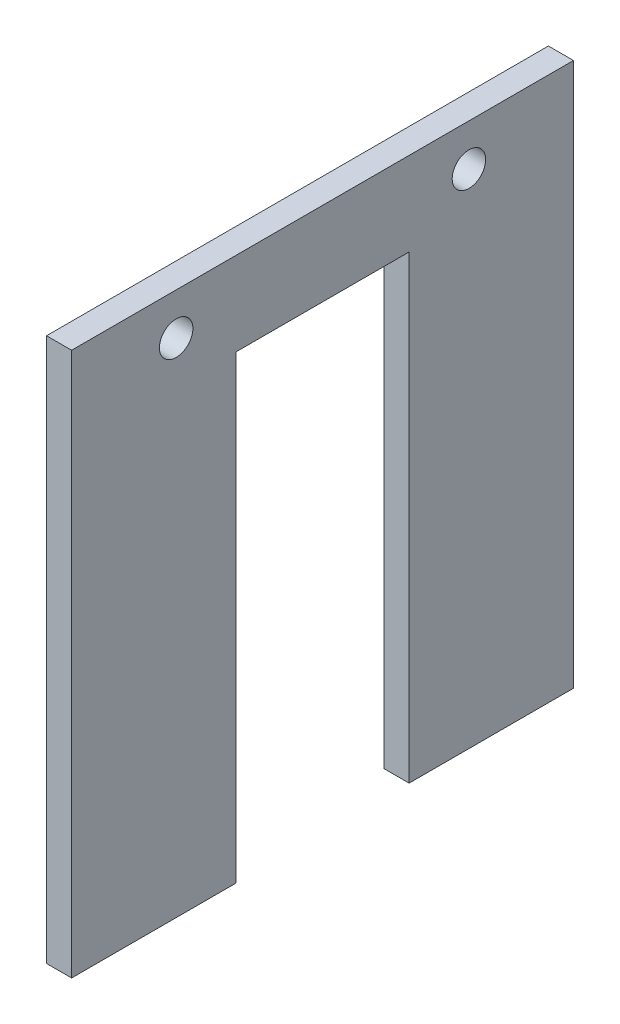
from build123d import *

# Parameters (mm, degrees)
SKETCH2_R           = 2
BOSS_EXTRUDE1_DEPTH = 3


with BuildPart() as part:
    # Sketch2 → Boss-Extrude1 (new body)
    with BuildSketch(Plane(origin=(0, 0, 0), x_dir=(0, 0, -1), z_dir=(1, 0, 0))):
        Polygon((60, 65), (0, 65), (0, 0), (19.65, 0), (19.65, 55), (40.35, 55), (40.35, 0), (60, 0), align=None)
        with Locations((12.5, 60)):
            Circle(SKETCH2_R, mode=Mode.SUBTRACT)
        with Locations((47.5, 60)):
            Circle(SKETCH2_R, mode=Mode.SUBTRACT)
    extrude(amount=BOSS_EXTRUDE1_DEPTH)


solid = part.part
